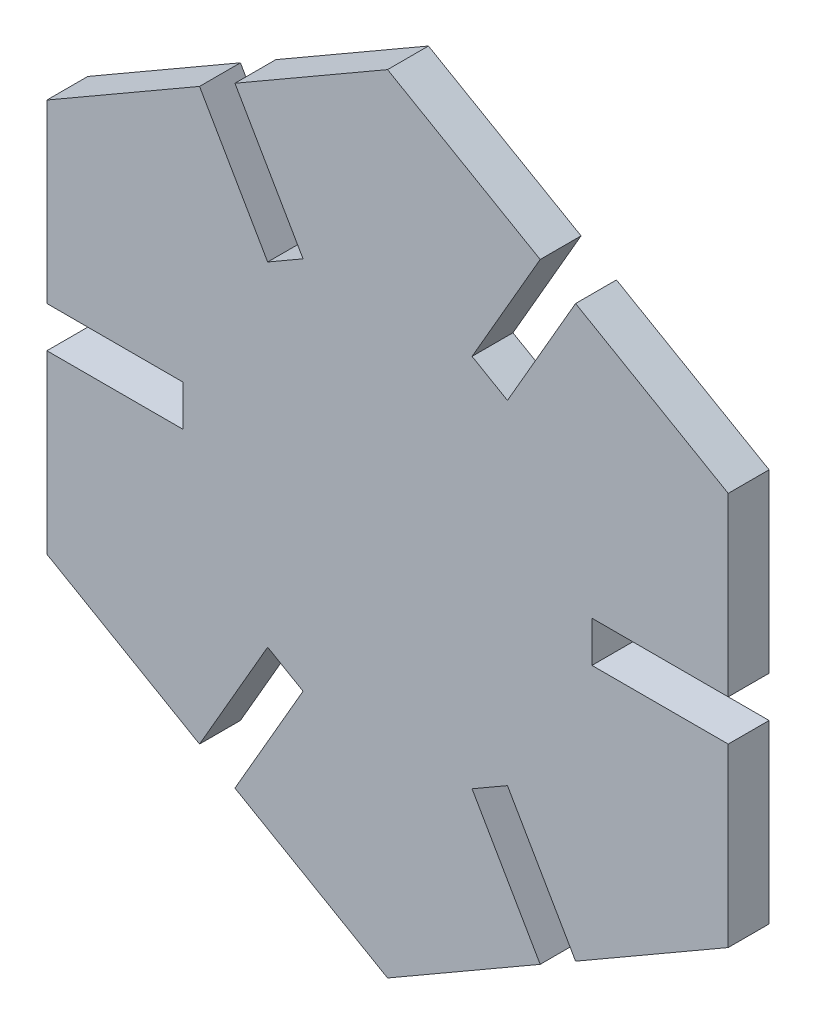
from build123d import *

# Parameters (mm, degrees)
BOSS_EXTRUDE1_DEPTH = 3


with BuildPart() as part:
    # Sketch1 → Boss-Extrude1 (new body)
    with BuildSketch(Plane.XY):
        Polygon((-13.799038106, 20.900635095), (-8.799038106, 12.240381057), (-6.200961894, 13.740381057), (-11.200961894, 22.400635095), (0, 28.867513459), (11.200961894, 22.400635095), (6.200961894, 13.740381057), (8.799038106, 12.240381057), (13.799038106, 20.900635095), (25, 14.43375673), (25, 1.5), (15, 1.5), (15, -1.5), (25, -1.5), (25, -14.43375673), (13.799038106, -20.900635095), (8.799038106, -12.240381057), (6.200961894, -13.740381057), (11.200961894, -22.400635095), (0, -28.867513459), (-11.200961894, -22.400635095), (-6.200961894, -13.740381057), (-8.799038106, -12.240381057), (-13.799038106, -20.900635095), (-25, -14.43375673), (-25, -1.5), (-15, -1.5), (-15, 1.5), (-25, 1.5), (-25, 14.43375673), align=None)
    extrude(amount=BOSS_EXTRUDE1_DEPTH)


solid = part.part
